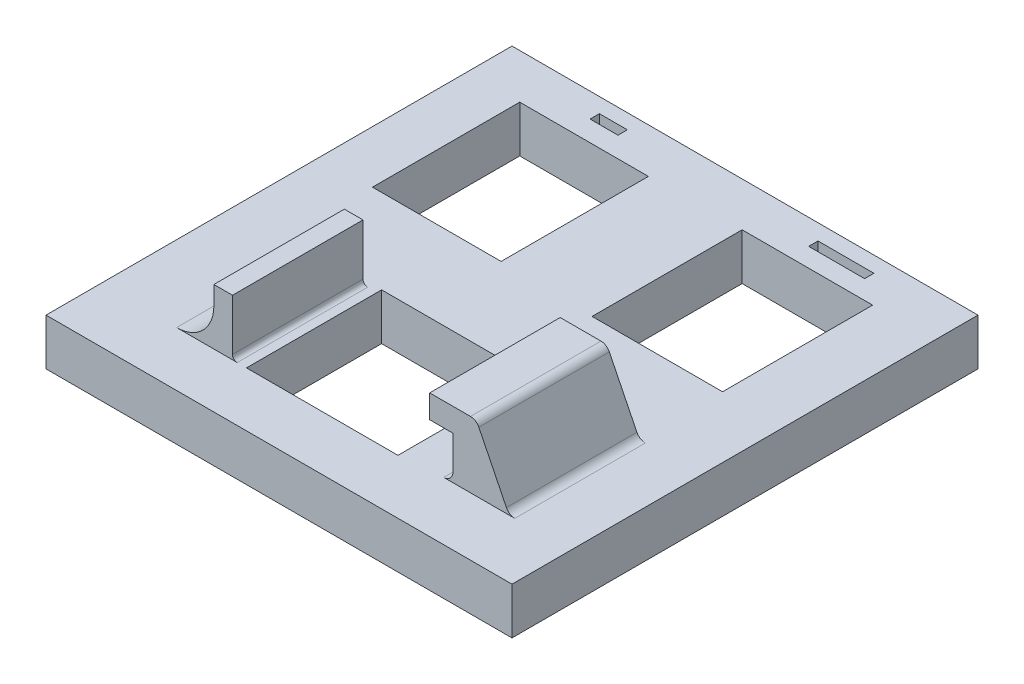
from build123d import *

# Parameters (mm, degrees)
SKETCH1_W           = 50
SKETCH1_H           = 25
BOSS_EXTRUDE1_DEPTH = 5
SKETCH2_W           = 13.8
SKETCH2_H           = 15.8
CUT_EXTRUDE1_DEPTH  = 5
SKETCH3_W           = 14
SKETCH3_H           = 16.1
CUT_EXTRUDE2_DEPTH  = 5
SKETCH5_W           = 3
SKETCH5_H           = 1
SKETCH5_W_2         = 6
CUT_EXTRUDE3_DEPTH  = 1
SKETCH6_W           = 50
SKETCH6_H           = 25
BOSS_EXTRUDE2_DEPTH = 5
SKETCH7_W           = 16.25
SKETCH7_H           = 14.5
CUT_EXTRUDE4_DEPTH  = 4
SKETCH8_W           = 14.75
SKETCH8_H           = 14.5
CUT_EXTRUDE5_DEPTH  = 1
SKETCH9_W           = 2.5
SKETCH9_H           = 14
BOSS_EXTRUDE3_DEPTH = 4.6
SKETCH10_W          = 5
SKETCH10_H          = 14
BOSS_EXTRUDE4_DEPTH = 2.5
BOSS_EXTRUDE5_DEPTH = 14
FILLET1_R           = 1
SKETCH12_W          = 2
SKETCH12_H          = 14
BOSS_EXTRUDE6_DEPTH = 6
FILLET2_R           = 4
FILLET3_R           = 1
FILLET4_R           = 0.5


with BuildPart() as part:
    # Sketch1 → Boss-Extrude1 (new body)
    with BuildSketch(Plane(origin=(0, 0, 0), x_dir=(1, 0, 0), z_dir=(0, 1, 0))):
        Rectangle(SKETCH1_W, SKETCH1_H)
    extrude(amount=BOSS_EXTRUDE1_DEPTH)

    # Sketch2 → Cut-Extrude1 (cut)
    with BuildSketch(Plane(origin=(0, 5, 0), x_dir=(1, 0, 0), z_dir=(0, 1, 0))):
        with Locations((-12.471632497, -0.196290121)):
            Rectangle(SKETCH2_W, SKETCH2_H)
    extrude(amount=-CUT_EXTRUDE1_DEPTH, mode=Mode.SUBTRACT)

    # Sketch3 → Cut-Extrude2 (cut)
    with BuildSketch(Plane(origin=(0, 5, 0), x_dir=(1, 0, 0), z_dir=(0, 1, 0))):
        with Locations((11.418853314, -0.27633095)):
            Rectangle(SKETCH3_W, SKETCH3_H)
    extrude(amount=-CUT_EXTRUDE2_DEPTH, mode=Mode.SUBTRACT)

    # Sketch5 → Cut-Extrude3 (cut)
    with BuildSketch(Plane(origin=(0, 5, 0), x_dir=(1, 0, 0), z_dir=(0, 1, 0))):
        with Locations((-12.529830787, 10.403858803)):
            Rectangle(SKETCH5_W, SKETCH5_H)
        with Locations((12.528710417, 10.30293358)):
            Rectangle(SKETCH5_W_2, SKETCH5_H)
    extrude(amount=-CUT_EXTRUDE3_DEPTH, mode=Mode.SUBTRACT)

    # Sketch6 → Boss-Extrude2 (add)
    with BuildSketch(Plane(origin=(0, 0, 0), x_dir=(1, 0, 0), z_dir=(0, 1, 0))):
        with Locations((0, -25)):
            Rectangle(SKETCH6_W, SKETCH6_H)
    extrude(amount=BOSS_EXTRUDE2_DEPTH)

    # Sketch7 → Cut-Extrude4 (cut)
    with BuildSketch(Plane(origin=(0, 5, 0), x_dir=(1, 0, 0), z_dir=(0, 1, 0))):
        with Locations((-1.214601825, -24.398968546)):
            Rectangle(SKETCH7_W, SKETCH7_H)
    extrude(amount=-CUT_EXTRUDE4_DEPTH, mode=Mode.SUBTRACT)

    # Sketch8 → Cut-Extrude5 (cut)
    with BuildSketch(Plane(origin=(0, 1, 0), x_dir=(1, 0, 0), z_dir=(0, 1, 0))):
        with Locations((-1.964601825, -24.398968546)):
            Rectangle(SKETCH8_W, SKETCH8_H)
    extrude(amount=-CUT_EXTRUDE5_DEPTH, mode=Mode.SUBTRACT)

    # Sketch9 → Boss-Extrude3 (add)
    with BuildSketch(Plane(origin=(0, 5, 0), x_dir=(1, 0, 0), z_dir=(0, 1, 0))):
        with Locations((13.660398175, -24.242407708)):
            Rectangle(SKETCH9_W, SKETCH9_H)
    extrude(amount=BOSS_EXTRUDE3_DEPTH)

    # Sketch10 → Boss-Extrude4 (add)
    with BuildSketch(Plane(origin=(0, 9.6, 0), x_dir=(1, 0, 0), z_dir=(0, 1, 0))):
        with Locations((12.410398175, -24.242407708)):
            Rectangle(SKETCH10_W, SKETCH10_H)
    extrude(amount=BOSS_EXTRUDE4_DEPTH)

    # Sketch11 → Boss-Extrude5 (add)
    with BuildSketch(Plane.XY.offset(31.242407708)):
        Polygon((14.910398175, 5), (18.418853314, 5), (14.910398175, 12.1), align=None)
    extrude(amount=-BOSS_EXTRUDE5_DEPTH)

    # Fillet1
    fillet1_edges = [part.edges().sort_by_distance(p)[0] for p in [
        (14.910398175, 12.1, 24.242407708),
        (18.418853314, 5, 24.242407708),
    ]]
    fillet(fillet1_edges, radius=FILLET1_R)

    # Sketch12 → Boss-Extrude6 (add)
    with BuildSketch(Plane(origin=(0, 5, 0), x_dir=(1, 0, 0), z_dir=(0, 1, 0))):
        with Locations((-11.839601825, -24.648968546)):
            Rectangle(SKETCH12_W, SKETCH12_H)
    extrude(amount=BOSS_EXTRUDE6_DEPTH)

    # Fillet2
    fillet2_edges = [part.edges().sort_by_distance(p)[0] for p in [
        (-12.839601825, 5, 24.648968546),
    ]]
    fillet(fillet2_edges, radius=FILLET2_R)

    # Fillet3
    fillet3_edges = [part.edges().sort_by_distance(p)[0] for p in [
        (12.410398175, 5, 24.242407708),
    ]]
    fillet(fillet3_edges, radius=FILLET3_R)

    # Fillet4
    fillet4_edges = [part.edges().sort_by_distance(p)[0] for p in [
        (-10.839601825, 5, 24.648968546),
    ]]
    fillet(fillet4_edges, radius=FILLET4_R)


solid = part.part
